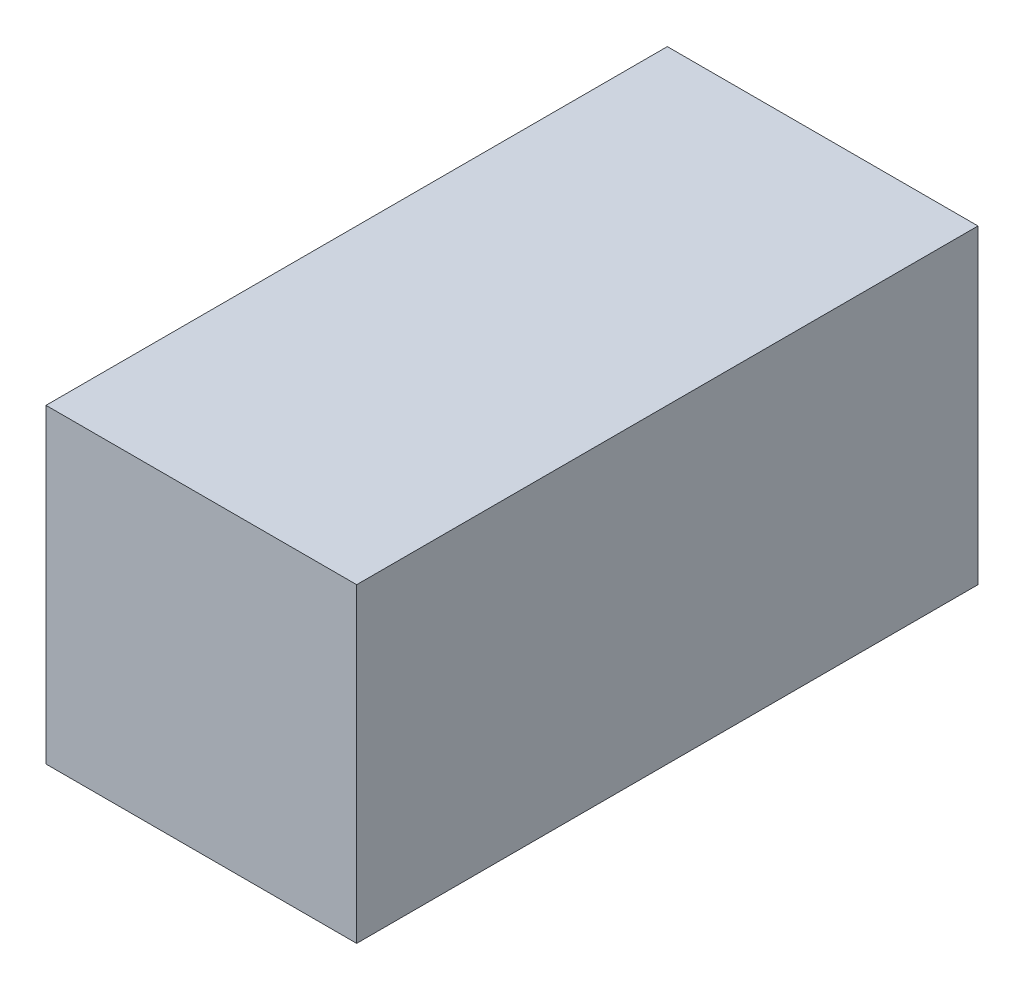
from build123d import *

# Parameters (mm, degrees)
SKETCH1_W           = 4
SKETCH1_H           = 4
BOSS_EXTRUDE1_DEPTH = 8


with BuildPart() as part:
    # Sketch1 → Boss-Extrude1 (new body)
    with BuildSketch(Plane.XY):
        Rectangle(SKETCH1_W, SKETCH1_H)
    extrude(amount=BOSS_EXTRUDE1_DEPTH)


solid = part.part
